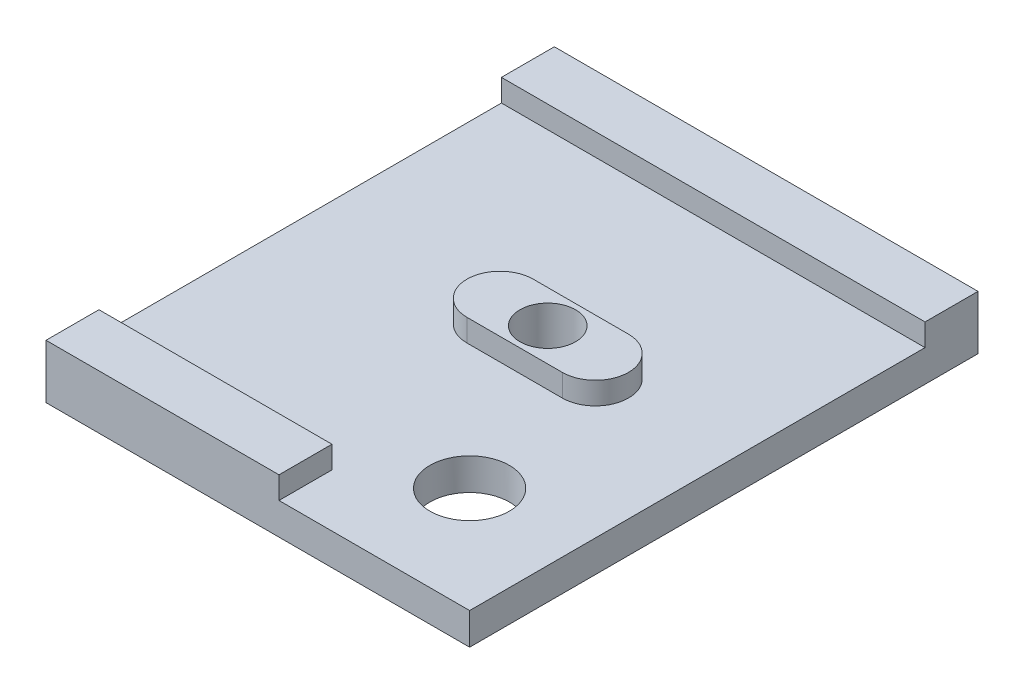
from build123d import *

# Parameters (mm, degrees)
SKETCH2_W               = 40
SKETCH2_H               = 48
BOSS_EXTRUDE3_DEPTH     = 3
SKETCH3_W               = 22
SKETCH3_H               = 5
SKETCH3_W_2             = 40
BOSS_EXTRUDE4_DEPTH     = 2.1
SKETCH4_R               = 2.625
CUT_EXTRUDE1_DEPTH      = 1
CUT_EXTRUDE1_DEPTH_BACK = 6.1
SKETCH5_R               = 3.75
CUT_EXTRUDE2_DEPTH      = 3.1
CUT_EXTRUDE2_DEPTH_BACK = 4


with BuildPart() as part:
    # Sketch2 → Boss-Extrude3 (new body)
    with BuildSketch(Plane(origin=(0, 0, 0), x_dir=(1, 0, 0), z_dir=(0, 1, 0))):
        Rectangle(SKETCH2_W, SKETCH2_H)
    extrude(amount=BOSS_EXTRUDE3_DEPTH)

    # Sketch3 → Boss-Extrude4 (add)
    with BuildSketch(Plane(origin=(0, 3, 0), x_dir=(1, 0, 0), z_dir=(0, 1, 0))):
        with Locations((-9, -21.5)):
            Rectangle(SKETCH3_W, SKETCH3_H)
        with BuildLine():
            ThreePointArc((1.125, 0.875), (0.209708691, 3.084708691), (-2, 4))
            Line((-2, 4), (-2, -2.25))
            ThreePointArc((-2, -2.25), (0.209708691, -1.334708691), (1.125, 0.875))
        make_face()
        with BuildLine():
            Line((-2, -2.25), (-2, 4))
            ThreePointArc((-2, 4), (-5.125, 0.875), (-2, -2.25))
        make_face()
        with BuildLine():
            ThreePointArc((10.125, 0.875), (9.209708691, 3.084708691), (7, 4))
            Line((7, 4), (7, -2.25))
            ThreePointArc((7, -2.25), (9.209708691, -1.334708691), (10.125, 0.875))
        make_face()
        with BuildLine():
            Line((7, -2.25), (7, 4))
            ThreePointArc((7, 4), (3.875, 0.875), (7, -2.25))
        make_face()
        with BuildLine():
            Line((7, 4), (-2, 4))
            ThreePointArc((-2, 4), (0.209708691, 3.084708691), (1.125, 0.875))
            ThreePointArc((1.125, 0.875), (0.209708691, -1.334708691), (-2, -2.25))
            Line((-2, -2.25), (7, -2.25))
            ThreePointArc((7, -2.25), (3.875, 0.875), (7, 4))
        make_face()
        with Locations((0, 21.5)):
            Rectangle(SKETCH3_W_2, SKETCH3_H)
    extrude(amount=BOSS_EXTRUDE4_DEPTH)

    # Sketch4 → Cut-Extrude1 (cut, two sides)
    with BuildSketch(Plane(origin=(0, 5.1, 0), x_dir=(1, 0, 0), z_dir=(0, 1, 0))) as cut_extrude1_sk:
        with Locations((2.5, 0.875)):
            Circle(SKETCH4_R)
    extrude(amount=CUT_EXTRUDE1_DEPTH, mode=Mode.SUBTRACT)
    extrude(cut_extrude1_sk.sketch, amount=-CUT_EXTRUDE1_DEPTH_BACK, mode=Mode.SUBTRACT)

    # Sketch5 → Cut-Extrude2 (cut, two sides)
    with BuildSketch(Plane(origin=(0, 3, 0), x_dir=(1, 0, 0), z_dir=(0, 1, 0))) as cut_extrude2_sk:
        with Locations((10, -14)):
            Circle(SKETCH5_R)
    extrude(amount=CUT_EXTRUDE2_DEPTH, mode=Mode.SUBTRACT)
    extrude(cut_extrude2_sk.sketch, amount=-CUT_EXTRUDE2_DEPTH_BACK, mode=Mode.SUBTRACT)


solid = part.part
